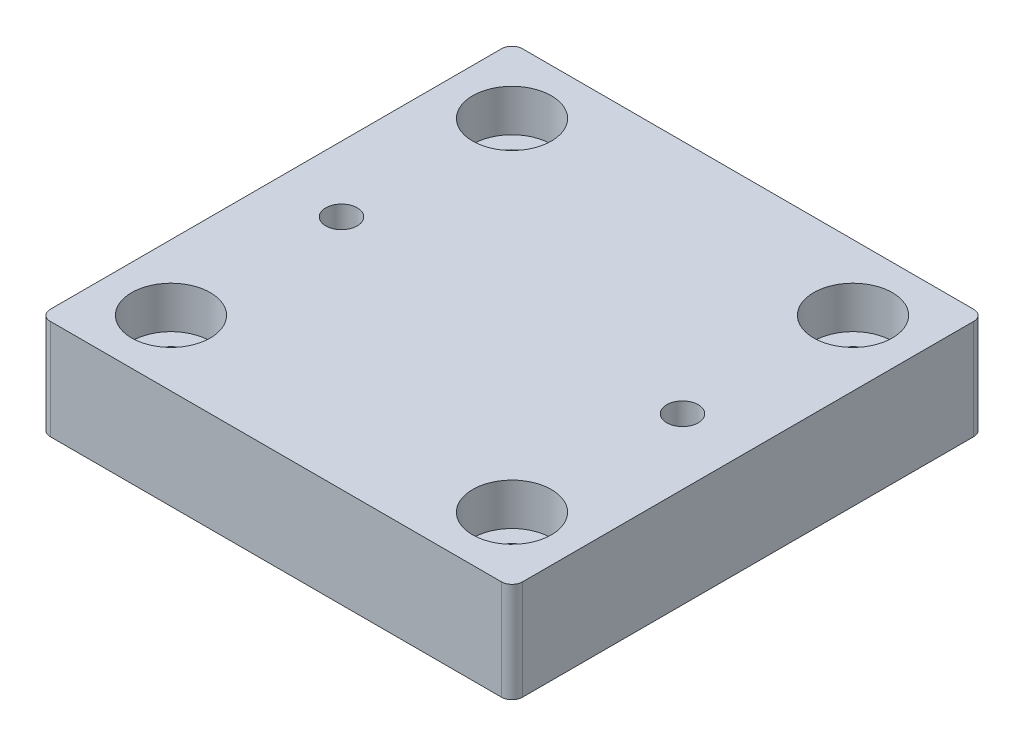
from build123d import *

# Parameters (mm, degrees)
SKETCH1_R           = 4
SKETCH1_R_2         = 3
BOSS_EXTRUDE1_DEPTH = 19.05
SKETCH2_R           = 7.5
CUT_EXTRUDE1_DEPTH  = 8


with BuildPart() as part:
    # Sketch1 → Boss-Extrude1 (new body)
    with BuildSketch(Plane(origin=(0, 0, 0), x_dir=(1, 0, 0), z_dir=(0, 1, 0))):
        with BuildLine():
            Line((-43, -45), (43, -45))
            ThreePointArc((43, -45), (44.414213562, -44.414213562), (45, -43))
            Line((45, -43), (45, 43))
            ThreePointArc((45, 43), (44.414213562, 44.414213562), (43, 45))
            Line((43, 45), (-43, 45))
            ThreePointArc((-43, 45), (-44.414213562, 44.414213562), (-45, 43))
            Line((-45, 43), (-45, -43))
            ThreePointArc((-45, -43), (-44.414213562, -44.414213562), (-43, -45))
        make_face()
        with Locations((-32.5, 32.5)):
            Circle(SKETCH1_R, mode=Mode.SUBTRACT)
        with Locations((32.5, 32.5)):
            Circle(SKETCH1_R, mode=Mode.SUBTRACT)
        with Locations((32.5, -32.5)):
            Circle(SKETCH1_R, mode=Mode.SUBTRACT)
        with Locations((-32.5, -32.5)):
            Circle(SKETCH1_R, mode=Mode.SUBTRACT)
        with Locations((-32.5, 0)):
            Circle(SKETCH1_R_2, mode=Mode.SUBTRACT)
        with Locations((32.5, 0)):
            Circle(SKETCH1_R_2, mode=Mode.SUBTRACT)
    extrude(amount=BOSS_EXTRUDE1_DEPTH)

    # Sketch2 → Cut-Extrude1 (cut)
    with BuildSketch(Plane(origin=(0, 19.05, 0), x_dir=(1, 0, 0), z_dir=(0, 1, 0))):
        with Locations((-32.5, -32.5)):
            Circle(SKETCH2_R)
        with Locations((32.5, -32.5)):
            Circle(SKETCH2_R)
        with Locations((32.5, 32.5)):
            Circle(SKETCH2_R)
        with Locations((-32.5, 32.5)):
            Circle(SKETCH2_R)
    extrude(amount=-CUT_EXTRUDE1_DEPTH, mode=Mode.SUBTRACT)


solid = part.part
